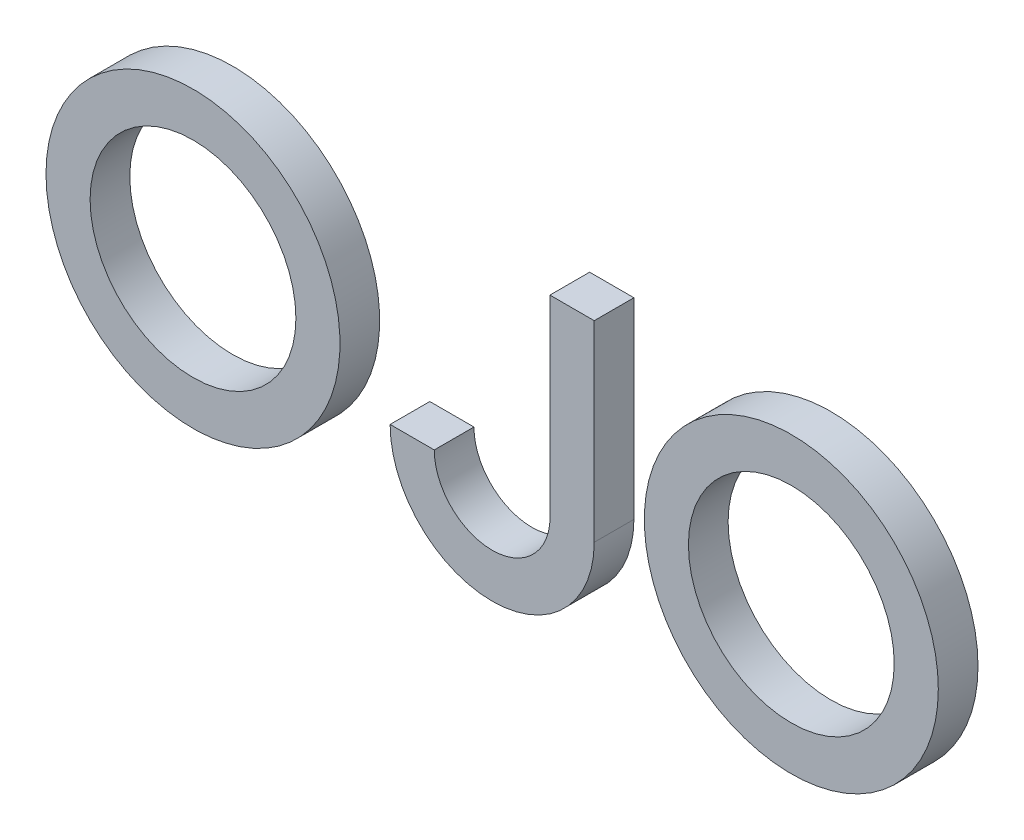
from build123d import *

# Parameters (mm, degrees)
SKETCH2_R             = 10
SKETCH2_R_2           = 7
BOSS_EXTRUDE1_DEPTH   = 2.7
BOSS_EXTRUDE1_2_DEPTH = 2.7
BOSS_EXTRUDE1_3_DEPTH = 2.7


with BuildPart() as part:
    # Sketch2 → Boss-Extrude1 (new body)
    with BuildSketch(Plane.XY):
        with Locations((20.351834019, 0)):
            Circle(SKETCH2_R)
        with Locations((20.351834019, 0)):
            Circle(SKETCH2_R_2, mode=Mode.SUBTRACT)
    extrude(amount=BOSS_EXTRUDE1_DEPTH)


with BuildPart() as body_2:
    # Sketch2 → Boss-Extrude1 2 (new body)
    with BuildSketch(Plane.XY):
        with Locations((-20.351834019, 0)):
            Circle(SKETCH2_R)
        with Locations((-20.351834019, 0)):
            Circle(SKETCH2_R_2, mode=Mode.SUBTRACT)
    extrude(amount=BOSS_EXTRUDE1_2_DEPTH)


with BuildPart() as body_3:
    # Sketch2 → Boss-Extrude1 3 (new body)
    with BuildSketch(Plane.XY):
        with BuildLine():
            Line((3.93040203, 10.000000001), (6.944018143, 10.000000001))
            Line((6.944018143, 10.000000001), (6.944018143, -3.056941252))
            ThreePointArc((6.944018143, -3.056941252), (0.000959328, -10.000000066), (-6.942099487, -3.056941252))
            Line((-6.942099487, -3.056941252), (-3.939040028, -3.056941252))
            ThreePointArc((-3.939040028, -3.056941252), (0.002552284, -6.996940286), (3.940957396, -3.053755339))
            Line((3.940957396, -3.053755339), (3.93040203, 10.000000001))
        make_face()
    extrude(amount=BOSS_EXTRUDE1_3_DEPTH)


solid = Compound([part.part, body_2.part, body_3.part])
